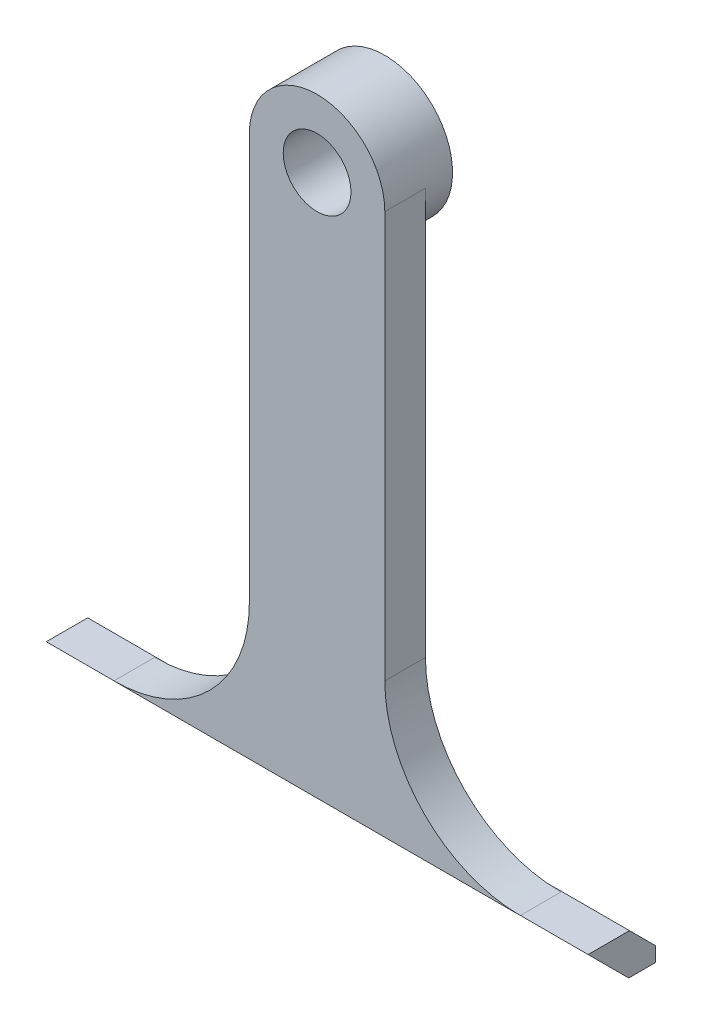
from build123d import *

# Parameters (mm, degrees)
SKETCH1_R           = 6.35
BOSS_EXTRUDE1_DEPTH = 7.62
BOSS_EXTRUDE2_START = -5.08
SKETCH4_R           = 6.35
BOSS_EXTRUDE2_DEPTH = 7.62
BOSS_EXTRUDE3_START = 0
SKETCH4_3_R         = 6.35
BOSS_EXTRUDE3_DEPTH = 5.08
FILLET1_R           = 25.4
CHAMFER1_SIZE       = 4.92
CUT_EXTRUDE1_DEPTH  = 161.724006919


with BuildPart() as part:
    # Sketch1 → Boss-Extrude1 (new body)
    with BuildSketch(Plane(origin=(0, 0, 0), x_dir=(1, 0, 0), z_dir=(0, 1, 0))):
        with BuildLine():
            Line((-50.8, 25.4), (50.8, 25.4))
            Line((50.8, 25.4), (50.8, 0))
            ThreePointArc((50.8, 0), (43.360512242, -17.960512242), (25.4, -25.4))
            Line((25.4, -25.4), (-25.4, -25.4))
            ThreePointArc((-25.4, -25.4), (-43.360512242, -17.960512242), (-50.8, 0))
            Line((-50.8, 0), (-50.8, 25.4))
        make_face()
        with Locations((-25.4, 0)):
            Circle(SKETCH1_R, mode=Mode.SUBTRACT)
        with Locations((25.4, 0)):
            Circle(SKETCH1_R, mode=Mode.SUBTRACT)
    extrude(amount=BOSS_EXTRUDE1_DEPTH)

    # Sketch4 → Boss-Extrude2 (add)
    with BuildSketch(Plane(origin=(0, 0, -25.4), x_dir=(-1, 0, 0), z_dir=(0, 0, -1)).offset(BOSS_EXTRUDE2_START)):
        with BuildLine():
            ThreePointArc((12.7, 109.22), (0, 121.92), (-12.7, 109.22))
            Line((-12.7, 109.22), (-12.7, 7.62))
            Line((-12.7, 7.62), (12.7, 7.62))
            Line((12.7, 7.62), (12.7, 109.22))
        make_face()
        with Locations((0, 109.22)):
            Circle(SKETCH4_R, mode=Mode.SUBTRACT)
    extrude(amount=-BOSS_EXTRUDE2_DEPTH)

    # Sketch4_3 → Boss-Extrude3 (add)
    with BuildSketch(Plane(origin=(0, 0, -25.4), x_dir=(-1, 0, 0), z_dir=(0, 0, -1)).offset(BOSS_EXTRUDE3_START)):
        with BuildLine():
            ThreePointArc((-12.7, 109.22), (0, 96.52), (12.7, 109.22))
            ThreePointArc((12.7, 109.22), (0, 121.92), (-12.7, 109.22))
        make_face()
        with Locations((0, 109.22)):
            Circle(SKETCH4_3_R, mode=Mode.SUBTRACT)
    extrude(amount=-BOSS_EXTRUDE3_DEPTH)

    # Fillet1
    fillet1_edges = [part.edges().sort_by_distance(p)[0] for p in [
        (-12.7, 7.62, -16.51),
        (12.7, 7.62, -16.51),
    ]]
    fillet(fillet1_edges, radius=FILLET1_R)

    # Chamfer1
    chamfer1_edges = [part.edges().sort_by_distance(p)[0] for p in [
        (0, 7.62, -25.4),
    ]]
    chamfer(chamfer1_edges, length=CHAMFER1_SIZE)

    # Sketch8 → Cut-Extrude1 (cut, through all)
    with BuildSketch(Plane(origin=(50.8, 0, 0), x_dir=(0, 0, -1), z_dir=(1, 0, 0))):
        Polygon((12.717540877, 7.62), (20.337540877, 0), (-26.584534345, 0), (-26.584534345, 7.62), align=None)
    extrude(amount=-CUT_EXTRUDE1_DEPTH, mode=Mode.SUBTRACT)


solid = part.part
